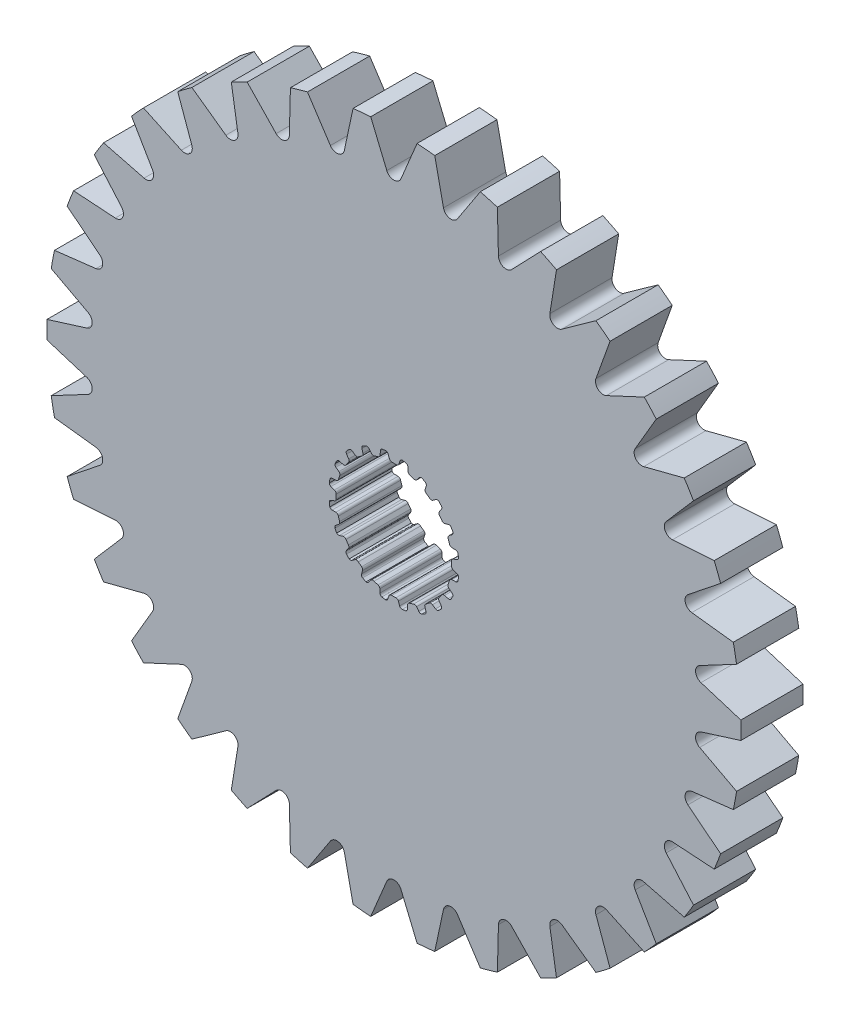
from build123d import *

# Parameters (mm, degrees)
SKETCH1_R           = 17.852401406
BOSS_EXTRUDE1_DEPTH = 1.6002
CUT_EXTRUDE1_DEPTH  = 3.2004


with BuildPart() as part:
    # Sketch1 → Boss-Extrude1 (new body, symmetric)
    with BuildSketch(Plane.XY):
        Circle(SKETCH1_R)
        with BuildLine():
            Line((-0.106949245, 2.969874934), (0.106949245, 2.969874934))
            ThreePointArc((0.106949245, 2.969874934), (0.196343213, 2.986924176), (0.253739238, 3.057547504))
            Line((0.253739238, 3.057547504), (0.315888147, 3.237526941))
            ThreePointArc((0.315888147, 3.237526941), (0.359032156, 3.298322911), (0.4281449, 3.326269005))
            Line((0.4281449, 3.326269005), (0.620027588, 3.2937547))
            ThreePointArc((0.620027588, 3.2937547), (0.689621142, 3.24802576), (0.718272212, 3.169836791))
            Line((0.718272212, 3.169836791), (0.724389167, 2.979527391))
            ThreePointArc((0.724389167, 2.979527391), (0.750934762, 2.9040661), (0.816027049, 2.857568043))
            Line((0.816027049, 2.857568043), (1.019456602, 2.791469774))
            ThreePointArc((1.019456602, 2.791469774), (1.109743823, 2.780060312), (1.186154496, 2.829490741))
            Line((1.186154496, 2.829490741), (1.300878326, 2.981456288))
            ThreePointArc((1.300878326, 2.981456288), (1.360697704, 3.02594446), (1.435063648, 3.031165762))
            Line((1.435063648, 3.031165762), (1.607507455, 2.940947809))
            ThreePointArc((1.607507455, 2.940947809), (1.659563839, 2.875951412), (1.662650905, 2.792735615))
            Line((1.662650905, 2.792735615), (1.609659636, 2.609850378))
            ThreePointArc((1.609659636, 2.609850378), (1.611587176, 2.529879385), (1.659124931, 2.465542482))
            Line((1.659124931, 2.465542482), (1.832172444, 2.339816104))
            ThreePointArc((1.832172444, 2.339816104), (1.914514976, 2.301064775), (2.002460687, 2.32446371))
            Line((2.002460687, 2.32446371), (2.158529469, 2.433539921))
            ThreePointArc((2.158529469, 2.433539921), (2.229168681, 2.457365482), (2.301508367, 2.439350895))
            Line((2.301508367, 2.439350895), (2.437633293, 2.300260456))
            ThreePointArc((2.437633293, 2.300260456), (2.467056864, 2.222358901), (2.444277744, 2.14226202))
            Line((2.444277744, 2.14226202), (2.337365406, 1.984703026))
            ThreePointArc((2.337365406, 1.984703026), (2.314486209, 1.908050449), (2.339816104, 1.832172444))
            Line((2.339816104, 1.832172444), (2.465542482, 1.659124931))
            ThreePointArc((2.465542482, 1.659124931), (2.531880064, 1.596824985), (2.622752074, 1.591901975))
            Line((2.622752074, 1.591901975), (2.804888709, 1.64741171))
            ThreePointArc((2.804888709, 1.64741171), (2.879433095, 1.648242449), (2.942665411, 1.608755366))
            Line((2.942665411, 1.608755366), (3.0291466, 1.434407582))
            ThreePointArc((3.0291466, 1.434407582), (3.033057175, 1.351226417), (2.986641646, 1.282088892))
            Line((2.986641646, 1.282088892), (2.836273564, 1.165279113))
            ThreePointArc((2.836273564, 1.165279113), (2.790827206, 1.099448241), (2.791469774, 1.019456602))
            Line((2.791469774, 1.019456602), (2.857568043, 0.816027049))
            ThreePointArc((2.857568043, 0.816027049), (2.901407091, 0.736276839), (2.986310214, 0.703513784))
            Line((2.986310214, 0.703513784), (3.1766859, 0.700023363))
            ThreePointArc((3.1766859, 0.700023363), (3.247838536, 0.677777961), (3.295773863, 0.620683653))
            Line((3.295773863, 0.620683653), (3.324145932, 0.4281449))
            ThreePointArc((3.324145932, 0.4281449), (3.302160717, 0.347826477), (3.236652255, 0.29641597))
            Line((3.236652255, 0.29641597), (3.057547504, 0.231789562))
            ThreePointArc((3.057547504, 0.231789562), (2.993982591, 0.183224379), (2.969874934, 0.106949245))
            Line((2.969874934, 0.106949245), (2.969874934, -0.106949245))
            ThreePointArc((2.969874934, -0.106949245), (2.986924176, -0.196343213), (3.057547504, -0.253739238))
            Line((3.057547504, -0.253739238), (3.237526941, -0.315888147))
            ThreePointArc((3.237526941, -0.315888147), (3.298322911, -0.359032156), (3.326269005, -0.4281449))
            Line((3.326269005, -0.4281449), (3.2937547, -0.620027588))
            ThreePointArc((3.2937547, -0.620027588), (3.24802576, -0.689621142), (3.169836791, -0.718272212))
            Line((3.169836791, -0.718272212), (2.979527391, -0.724389167))
            ThreePointArc((2.979527391, -0.724389167), (2.9040661, -0.750934762), (2.857568043, -0.816027049))
            Line((2.857568043, -0.816027049), (2.791469774, -1.019456602))
            ThreePointArc((2.791469774, -1.019456602), (2.780060312, -1.109743823), (2.829490741, -1.186154496))
            Line((2.829490741, -1.186154496), (2.981456288, -1.300878326))
            ThreePointArc((2.981456288, -1.300878326), (3.02594446, -1.360697704), (3.031165762, -1.435063648))
            Line((3.031165762, -1.435063648), (2.940947809, -1.607507455))
            ThreePointArc((2.940947809, -1.607507455), (2.875951412, -1.659563839), (2.792735615, -1.662650905))
            Line((2.792735615, -1.662650905), (2.609850378, -1.609659636))
            ThreePointArc((2.609850378, -1.609659636), (2.529879385, -1.611587176), (2.465542482, -1.659124931))
            Line((2.465542482, -1.659124931), (2.339816104, -1.832172444))
            ThreePointArc((2.339816104, -1.832172444), (2.301064775, -1.914514976), (2.32446371, -2.002460687))
            Line((2.32446371, -2.002460687), (2.433539921, -2.158529469))
            ThreePointArc((2.433539921, -2.158529469), (2.457365482, -2.229168681), (2.439350895, -2.301508367))
            Line((2.439350895, -2.301508367), (2.300260456, -2.437633293))
            ThreePointArc((2.300260456, -2.437633293), (2.222358901, -2.467056864), (2.14226202, -2.444277744))
            Line((2.14226202, -2.444277744), (1.984703026, -2.337365406))
            ThreePointArc((1.984703026, -2.337365406), (1.908050449, -2.314486209), (1.832172444, -2.339816104))
            Line((1.832172444, -2.339816104), (1.659124931, -2.465542482))
            ThreePointArc((1.659124931, -2.465542482), (1.596824985, -2.531880064), (1.591901975, -2.622752074))
            Line((1.591901975, -2.622752074), (1.64741171, -2.804888709))
            ThreePointArc((1.64741171, -2.804888709), (1.648242449, -2.879433095), (1.608755366, -2.942665411))
            Line((1.608755366, -2.942665411), (1.434407582, -3.0291466))
            ThreePointArc((1.434407582, -3.0291466), (1.351226417, -3.033057175), (1.282088892, -2.986641646))
            Line((1.282088892, -2.986641646), (1.165279113, -2.836273564))
            ThreePointArc((1.165279113, -2.836273564), (1.099448241, -2.790827206), (1.019456602, -2.791469774))
            Line((1.019456602, -2.791469774), (0.816027049, -2.857568043))
            ThreePointArc((0.816027049, -2.857568043), (0.736276839, -2.901407091), (0.703513784, -2.986310214))
            Line((0.703513784, -2.986310214), (0.700023363, -3.1766859))
            ThreePointArc((0.700023363, -3.1766859), (0.677777961, -3.247838536), (0.620683653, -3.295773863))
            Line((0.620683653, -3.295773863), (0.4281449, -3.324145932))
            ThreePointArc((0.4281449, -3.324145932), (0.347826477, -3.302160717), (0.29641597, -3.236652255))
            Line((0.29641597, -3.236652255), (0.231789562, -3.057547504))
            ThreePointArc((0.231789562, -3.057547504), (0.183224379, -2.993982591), (0.106949245, -2.969874934))
            Line((0.106949245, -2.969874934), (-0.106949245, -2.969874934))
            ThreePointArc((-0.106949245, -2.969874934), (-0.196343213, -2.986924176), (-0.253739238, -3.057547504))
            Line((-0.253739238, -3.057547504), (-0.315888147, -3.237526941))
            ThreePointArc((-0.315888147, -3.237526941), (-0.359032156, -3.298322911), (-0.4281449, -3.326269005))
            Line((-0.4281449, -3.326269005), (-0.620027588, -3.2937547))
            ThreePointArc((-0.620027588, -3.2937547), (-0.689621142, -3.24802576), (-0.718272212, -3.169836791))
            Line((-0.718272212, -3.169836791), (-0.724389167, -2.979527391))
            ThreePointArc((-0.724389167, -2.979527391), (-0.750934762, -2.9040661), (-0.816027049, -2.857568043))
            Line((-0.816027049, -2.857568043), (-1.019456602, -2.791469774))
            ThreePointArc((-1.019456602, -2.791469774), (-1.109743823, -2.780060312), (-1.186154496, -2.829490741))
            Line((-1.186154496, -2.829490741), (-1.300878326, -2.981456288))
            ThreePointArc((-1.300878326, -2.981456288), (-1.360697704, -3.02594446), (-1.435063648, -3.031165762))
            Line((-1.435063648, -3.031165762), (-1.607507455, -2.940947809))
            ThreePointArc((-1.607507455, -2.940947809), (-1.659563839, -2.875951412), (-1.662650905, -2.792735615))
            Line((-1.662650905, -2.792735615), (-1.609659636, -2.609850378))
            ThreePointArc((-1.609659636, -2.609850378), (-1.611587176, -2.529879385), (-1.659124931, -2.465542482))
            Line((-1.659124931, -2.465542482), (-1.832172444, -2.339816104))
            ThreePointArc((-1.832172444, -2.339816104), (-1.914514976, -2.301064775), (-2.002460687, -2.32446371))
            Line((-2.002460687, -2.32446371), (-2.158529469, -2.433539921))
            ThreePointArc((-2.158529469, -2.433539921), (-2.229168681, -2.457365482), (-2.301508367, -2.439350895))
            Line((-2.301508367, -2.439350895), (-2.437633293, -2.300260456))
            ThreePointArc((-2.437633293, -2.300260456), (-2.467056864, -2.222358901), (-2.444277744, -2.14226202))
            Line((-2.444277744, -2.14226202), (-2.337365406, -1.984703026))
            ThreePointArc((-2.337365406, -1.984703026), (-2.314486209, -1.908050449), (-2.339816104, -1.832172444))
            Line((-2.339816104, -1.832172444), (-2.465542482, -1.659124931))
            ThreePointArc((-2.465542482, -1.659124931), (-2.531880064, -1.596824985), (-2.622752074, -1.591901975))
            Line((-2.622752074, -1.591901975), (-2.804888709, -1.64741171))
            ThreePointArc((-2.804888709, -1.64741171), (-2.879433095, -1.648242449), (-2.942665411, -1.608755366))
            Line((-2.942665411, -1.608755366), (-3.0291466, -1.434407582))
            ThreePointArc((-3.0291466, -1.434407582), (-3.033057175, -1.351226417), (-2.986641646, -1.282088892))
            Line((-2.986641646, -1.282088892), (-2.836273564, -1.165279113))
            ThreePointArc((-2.836273564, -1.165279113), (-2.790827206, -1.099448241), (-2.791469774, -1.019456602))
            Line((-2.791469774, -1.019456602), (-2.857568043, -0.816027049))
            ThreePointArc((-2.857568043, -0.816027049), (-2.901407091, -0.736276839), (-2.986310214, -0.703513784))
            Line((-2.986310214, -0.703513784), (-3.1766859, -0.700023363))
            ThreePointArc((-3.1766859, -0.700023363), (-3.247838536, -0.677777961), (-3.295773863, -0.620683653))
            Line((-3.295773863, -0.620683653), (-3.324145932, -0.4281449))
            ThreePointArc((-3.324145932, -0.4281449), (-3.302160717, -0.347826477), (-3.236652255, -0.29641597))
            Line((-3.236652255, -0.29641597), (-3.057547504, -0.231789562))
            ThreePointArc((-3.057547504, -0.231789562), (-2.993982591, -0.183224379), (-2.969874934, -0.106949245))
            Line((-2.969874934, -0.106949245), (-2.969874934, 0.106949245))
            ThreePointArc((-2.969874934, 0.106949245), (-2.986924176, 0.196343213), (-3.057547504, 0.253739238))
            Line((-3.057547504, 0.253739238), (-3.237526941, 0.315888147))
            ThreePointArc((-3.237526941, 0.315888147), (-3.298322911, 0.359032156), (-3.326269005, 0.4281449))
            Line((-3.326269005, 0.4281449), (-3.2937547, 0.620027588))
            ThreePointArc((-3.2937547, 0.620027588), (-3.24802576, 0.689621142), (-3.169836791, 0.718272212))
            Line((-3.169836791, 0.718272212), (-2.979527391, 0.724389167))
            ThreePointArc((-2.979527391, 0.724389167), (-2.9040661, 0.750934762), (-2.857568043, 0.816027049))
            Line((-2.857568043, 0.816027049), (-2.791469774, 1.019456602))
            ThreePointArc((-2.791469774, 1.019456602), (-2.780060312, 1.109743823), (-2.829490741, 1.186154496))
            Line((-2.829490741, 1.186154496), (-2.981456288, 1.300878326))
            ThreePointArc((-2.981456288, 1.300878326), (-3.02594446, 1.360697704), (-3.031165762, 1.435063648))
            Line((-3.031165762, 1.435063648), (-2.940947809, 1.607507455))
            ThreePointArc((-2.940947809, 1.607507455), (-2.875951412, 1.659563839), (-2.792735615, 1.662650905))
            Line((-2.792735615, 1.662650905), (-2.609850378, 1.609659636))
            ThreePointArc((-2.609850378, 1.609659636), (-2.529879385, 1.611587176), (-2.465542482, 1.659124931))
            Line((-2.465542482, 1.659124931), (-2.339816104, 1.832172444))
            ThreePointArc((-2.339816104, 1.832172444), (-2.301064775, 1.914514976), (-2.32446371, 2.002460687))
            Line((-2.32446371, 2.002460687), (-2.433539921, 2.158529469))
            ThreePointArc((-2.433539921, 2.158529469), (-2.457365482, 2.229168681), (-2.439350895, 2.301508367))
            Line((-2.439350895, 2.301508367), (-2.300260456, 2.437633293))
            ThreePointArc((-2.300260456, 2.437633293), (-2.222358901, 2.467056864), (-2.14226202, 2.444277744))
            Line((-2.14226202, 2.444277744), (-1.984703026, 2.337365406))
            ThreePointArc((-1.984703026, 2.337365406), (-1.908050449, 2.314486209), (-1.832172444, 2.339816104))
            Line((-1.832172444, 2.339816104), (-1.659124931, 2.465542482))
            ThreePointArc((-1.659124931, 2.465542482), (-1.596824985, 2.531880064), (-1.591901975, 2.622752074))
            Line((-1.591901975, 2.622752074), (-1.64741171, 2.804888709))
            ThreePointArc((-1.64741171, 2.804888709), (-1.648242449, 2.879433095), (-1.608755366, 2.942665411))
            Line((-1.608755366, 2.942665411), (-1.434407582, 3.0291466))
            ThreePointArc((-1.434407582, 3.0291466), (-1.351226417, 3.033057175), (-1.282088892, 2.986641646))
            Line((-1.282088892, 2.986641646), (-1.165279113, 2.836273564))
            ThreePointArc((-1.165279113, 2.836273564), (-1.099448241, 2.790827206), (-1.019456602, 2.791469774))
            Line((-1.019456602, 2.791469774), (-0.816027049, 2.857568043))
            ThreePointArc((-0.816027049, 2.857568043), (-0.736276839, 2.901407091), (-0.703513784, 2.986310214))
            Line((-0.703513784, 2.986310214), (-0.700023363, 3.1766859))
            ThreePointArc((-0.700023363, 3.1766859), (-0.677777961, 3.247838536), (-0.620683653, 3.295773863))
            Line((-0.620683653, 3.295773863), (-0.4281449, 3.324145932))
            ThreePointArc((-0.4281449, 3.324145932), (-0.347826477, 3.302160717), (-0.29641597, 3.236652255))
            Line((-0.29641597, 3.236652255), (-0.231789562, 3.057547504))
            ThreePointArc((-0.231789562, 3.057547504), (-0.183224379, 2.993982591), (-0.106949245, 2.969874934))
        make_face(mode=Mode.SUBTRACT)
    extrude(amount=BOSS_EXTRUDE1_DEPTH, both=True)

    # Sketch2 → Cut-Extrude1 (cut)
    with BuildSketch(Plane.XY.offset(1.6002)):
        with BuildLine():
            Line((-1.192370651, 17.812537388), (-0.364649349, 15.828937231))
            ThreePointArc((-0.364649349, 15.828937231), (0, 15.585975766), (0.364649349, 15.828937231))
            Line((0.364649349, 15.828937231), (1.192370651, 17.812537388))
            ThreePointArc((1.192370651, 17.812537388), (0, 17.852401406), (-1.192370651, 17.812537388))
        make_face()
        with BuildLine():
            Line((4.445113431, 17.290147557), (3.267000085, 15.492415353))
            ThreePointArc((3.267000085, 15.492415353), (2.863915532, 15.32059491), (2.550119083, 15.626423637))
            Line((2.550119083, 15.626423637), (2.100976882, 17.728342621))
            ThreePointArc((2.100976882, 17.728342621), (3.28037015, 17.548430347), (4.445113431, 17.290147557))
        make_face()
        with BuildLine():
            Line((7.546483204, 16.178962488), (6.058097051, 14.628317851))
            ThreePointArc((6.058097051, 14.628317851), (5.630303855, 14.53348957), (5.378046268, 14.891770928))
            Line((5.378046268, 14.891770928), (5.322778166, 17.04043041))
            ThreePointArc((5.322778166, 17.04043041), (6.449031229, 16.646868539), (7.546483204, 16.178962488))
        make_face()
        with BuildLine():
            Line((10.390866543, 14.516822257), (8.642892788, 13.266070529))
            ThreePointArc((8.642892788, 13.266070529), (8.204958933, 13.251463673), (8.022830537, 13.64999682))
            Line((8.022830537, 13.64999682), (8.363318624, 15.772226778))
            ThreePointArc((8.363318624, 15.772226778), (9.398078285, 15.178417589), (10.390866543, 14.516822257))
        make_face()
        with BuildLine():
            Line((12.881401384, 12.360329055), (10.933365177, 11.452063086))
            ThreePointArc((10.933365177, 11.452063086), (10.500203976, 11.518175075), (10.394406936, 11.943388442))
            Line((10.394406936, 11.943388442), (11.119056297, 13.966918881))
            ThreePointArc((11.119056297, 13.966918881), (12.027085056, 13.193083833), (12.881401384, 12.360329055))
        make_face()
        with BuildLine():
            Line((14.93327555, 9.782919671), (12.851514928, 9.24806937))
            ThreePointArc((12.851514928, 9.24806937), (12.437877165, 9.392648838), (12.412014272, 9.830062295))
            Line((12.412014272, 9.830062295), (13.496147843, 11.685984312))
            ThreePointArc((13.496147843, 11.685984312), (14.24652387, 10.75847543), (14.93327555, 9.782919671))
        make_face()
        with BuildLine():
            Line((16.476614929, 6.872364691), (14.332021752, 6.729143744))
            ThreePointArc((14.332021752, 6.729143744), (13.951993366, 6.947267211), (14.006945349, 7.381985167))
            Line((14.006945349, 7.381985167), (15.413644262, 9.007097564))
            ThreePointArc((15.413644262, 9.007097564), (15.980814401, 7.957500049), (16.476614929, 6.872364691))
        make_face()
        with BuildLine():
            Line((17.458862947, 3.727779574), (15.324468765, 3.981065198))
            ThreePointArc((15.324468765, 3.981065198), (14.990991166, 4.265304731), (15.124886702, 4.682523387))
            Line((15.124886702, 4.682523387), (16.806247512, 6.02148491))
            ThreePointArc((16.806247512, 6.02148491), (17.170897464, 4.885541549), (17.458862947, 3.727779574))
        make_face()
        with BuildLine():
            Line((17.846570327, 0.456249395), (15.795059373, 1.097416251))
            ThreePointArc((15.795059373, 1.097416251), (15.519488741, 1.438092415), (15.727768178, 1.82360389))
            Line((15.727768178, 1.82360389), (17.626534159, 2.83081781))
            ThreePointArc((17.626534159, 2.83081781), (17.776246209, 1.64721179), (17.846570327, 0.456249395))
        make_face()
        with BuildLine():
            Line((17.626534159, -2.83081781), (15.727768178, -1.82360389))
            ThreePointArc((15.727768178, -1.82360389), (15.519488741, -1.438092415), (15.795059373, -1.097416251))
            Line((15.795059373, -1.097416251), (17.846570327, -0.456249395))
            ThreePointArc((17.846570327, -0.456249395), (17.776246209, -1.64721179), (17.626534159, -2.83081781))
        make_face()
        with BuildLine():
            Line((16.806247512, -6.02148491), (15.124886702, -4.682523387))
            ThreePointArc((15.124886702, -4.682523387), (14.990991166, -4.265304731), (15.324468765, -3.981065198))
            Line((15.324468765, -3.981065198), (17.458862947, -3.727779574))
            ThreePointArc((17.458862947, -3.727779574), (17.170897464, -4.885541549), (16.806247512, -6.02148491))
        make_face()
        with BuildLine():
            Line((15.413644262, -9.007097564), (14.006945349, -7.381985167))
            ThreePointArc((14.006945349, -7.381985167), (13.951993366, -6.947267211), (14.332021752, -6.729143744))
            Line((14.332021752, -6.729143744), (16.476614929, -6.872364691))
            ThreePointArc((16.476614929, -6.872364691), (15.980814401, -7.957500049), (15.413644262, -9.007097564))
        make_face()
        with BuildLine():
            Line((13.496147843, -11.685984312), (12.412014272, -9.830062295))
            ThreePointArc((12.412014272, -9.830062295), (12.437877165, -9.392648838), (12.851514928, -9.24806937))
            Line((12.851514928, -9.24806937), (14.93327555, -9.782919671))
            ThreePointArc((14.93327555, -9.782919671), (14.24652387, -10.75847543), (13.496147843, -11.685984312))
        make_face()
        with BuildLine():
            Line((11.119056297, -13.966918881), (10.394406936, -11.943388442))
            ThreePointArc((10.394406936, -11.943388442), (10.500203976, -11.518175075), (10.933365177, -11.452063086))
            Line((10.933365177, -11.452063086), (12.881401384, -12.360329055))
            ThreePointArc((12.881401384, -12.360329055), (12.027085056, -13.193083833), (11.119056297, -13.966918881))
        make_face()
        with BuildLine():
            Line((8.363318624, -15.772226778), (8.022830537, -13.64999682))
            ThreePointArc((8.022830537, -13.64999682), (8.204958933, -13.251463673), (8.642892788, -13.266070529))
            Line((8.642892788, -13.266070529), (10.390866543, -14.516822257))
            ThreePointArc((10.390866543, -14.516822257), (9.398078285, -15.178417589), (8.363318624, -15.772226778))
        make_face()
        with BuildLine():
            Line((5.322778166, -17.04043041), (5.378046268, -14.891770928))
            ThreePointArc((5.378046268, -14.891770928), (5.630303855, -14.53348957), (6.058097051, -14.628317851))
            Line((6.058097051, -14.628317851), (7.546483204, -16.178962488))
            ThreePointArc((7.546483204, -16.178962488), (6.449031229, -16.646868539), (5.322778166, -17.04043041))
        make_face()
        with BuildLine():
            Line((2.100976882, -17.728342621), (2.550119083, -15.626423637))
            ThreePointArc((2.550119083, -15.626423637), (2.863915532, -15.32059491), (3.267000085, -15.492415353))
            Line((3.267000085, -15.492415353), (4.445113431, -17.290147557))
            ThreePointArc((4.445113431, -17.290147557), (3.28037015, -17.548430347), (2.100976882, -17.728342621))
        make_face()
        with BuildLine():
            Line((-1.192370651, -17.812537388), (-0.364649349, -15.828937231))
            ThreePointArc((-0.364649349, -15.828937231), (0, -15.585975766), (0.364649349, -15.828937231))
            Line((0.364649349, -15.828937231), (1.192370651, -17.812537388))
            ThreePointArc((1.192370651, -17.812537388), (0, -17.852401406), (-1.192370651, -17.812537388))
        make_face()
        with BuildLine():
            Line((-4.445113431, -17.290147557), (-3.267000085, -15.492415353))
            ThreePointArc((-3.267000085, -15.492415353), (-2.863915532, -15.32059491), (-2.550119083, -15.626423637))
            Line((-2.550119083, -15.626423637), (-2.100976882, -17.728342621))
            ThreePointArc((-2.100976882, -17.728342621), (-3.28037015, -17.548430347), (-4.445113431, -17.290147557))
        make_face()
        with BuildLine():
            Line((-7.546483204, -16.178962488), (-6.058097051, -14.628317851))
            ThreePointArc((-6.058097051, -14.628317851), (-5.630303855, -14.53348957), (-5.378046268, -14.891770928))
            Line((-5.378046268, -14.891770928), (-5.322778166, -17.04043041))
            ThreePointArc((-5.322778166, -17.04043041), (-6.449031229, -16.646868539), (-7.546483204, -16.178962488))
        make_face()
        with BuildLine():
            Line((-10.390866543, -14.516822257), (-8.642892788, -13.266070529))
            ThreePointArc((-8.642892788, -13.266070529), (-8.204958933, -13.251463673), (-8.022830537, -13.64999682))
            Line((-8.022830537, -13.64999682), (-8.363318624, -15.772226778))
            ThreePointArc((-8.363318624, -15.772226778), (-9.398078285, -15.178417589), (-10.390866543, -14.516822257))
        make_face()
        with BuildLine():
            Line((-12.881401384, -12.360329055), (-10.933365177, -11.452063086))
            ThreePointArc((-10.933365177, -11.452063086), (-10.500203976, -11.518175075), (-10.394406936, -11.943388442))
            Line((-10.394406936, -11.943388442), (-11.119056297, -13.966918881))
            ThreePointArc((-11.119056297, -13.966918881), (-12.027085056, -13.193083833), (-12.881401384, -12.360329055))
        make_face()
        with BuildLine():
            Line((-14.93327555, -9.782919671), (-12.851514928, -9.24806937))
            ThreePointArc((-12.851514928, -9.24806937), (-12.437877165, -9.392648838), (-12.412014272, -9.830062295))
            Line((-12.412014272, -9.830062295), (-13.496147843, -11.685984312))
            ThreePointArc((-13.496147843, -11.685984312), (-14.24652387, -10.75847543), (-14.93327555, -9.782919671))
        make_face()
        with BuildLine():
            Line((-16.476614929, -6.872364691), (-14.332021752, -6.729143744))
            ThreePointArc((-14.332021752, -6.729143744), (-13.951993366, -6.947267211), (-14.006945349, -7.381985167))
            Line((-14.006945349, -7.381985167), (-15.413644262, -9.007097564))
            ThreePointArc((-15.413644262, -9.007097564), (-15.980814401, -7.957500049), (-16.476614929, -6.872364691))
        make_face()
        with BuildLine():
            Line((-17.458862947, -3.727779574), (-15.324468765, -3.981065198))
            ThreePointArc((-15.324468765, -3.981065198), (-14.990991166, -4.265304731), (-15.124886702, -4.682523387))
            Line((-15.124886702, -4.682523387), (-16.806247512, -6.02148491))
            ThreePointArc((-16.806247512, -6.02148491), (-17.170897464, -4.885541549), (-17.458862947, -3.727779574))
        make_face()
        with BuildLine():
            Line((-17.846570327, -0.456249395), (-15.795059373, -1.097416251))
            ThreePointArc((-15.795059373, -1.097416251), (-15.519488741, -1.438092415), (-15.727768178, -1.82360389))
            Line((-15.727768178, -1.82360389), (-17.626534159, -2.83081781))
            ThreePointArc((-17.626534159, -2.83081781), (-17.776246209, -1.64721179), (-17.846570327, -0.456249395))
        make_face()
        with BuildLine():
            Line((-17.626534159, 2.83081781), (-15.727768178, 1.82360389))
            ThreePointArc((-15.727768178, 1.82360389), (-15.519488741, 1.438092415), (-15.795059373, 1.097416251))
            Line((-15.795059373, 1.097416251), (-17.846570327, 0.456249395))
            ThreePointArc((-17.846570327, 0.456249395), (-17.776246209, 1.64721179), (-17.626534159, 2.83081781))
        make_face()
        with BuildLine():
            Line((-16.806247512, 6.02148491), (-15.124886702, 4.682523387))
            ThreePointArc((-15.124886702, 4.682523387), (-14.990991166, 4.265304731), (-15.324468765, 3.981065198))
            Line((-15.324468765, 3.981065198), (-17.458862947, 3.727779574))
            ThreePointArc((-17.458862947, 3.727779574), (-17.170897464, 4.885541549), (-16.806247512, 6.02148491))
        make_face()
        with BuildLine():
            Line((-15.413644262, 9.007097564), (-14.006945349, 7.381985167))
            ThreePointArc((-14.006945349, 7.381985167), (-13.951993366, 6.947267211), (-14.332021752, 6.729143744))
            Line((-14.332021752, 6.729143744), (-16.476614929, 6.872364691))
            ThreePointArc((-16.476614929, 6.872364691), (-15.980814401, 7.957500049), (-15.413644262, 9.007097564))
        make_face()
        with BuildLine():
            Line((-13.496147843, 11.685984312), (-12.412014272, 9.830062295))
            ThreePointArc((-12.412014272, 9.830062295), (-12.437877165, 9.392648838), (-12.851514928, 9.24806937))
            Line((-12.851514928, 9.24806937), (-14.93327555, 9.782919671))
            ThreePointArc((-14.93327555, 9.782919671), (-14.24652387, 10.75847543), (-13.496147843, 11.685984312))
        make_face()
        with BuildLine():
            Line((-11.119056297, 13.966918881), (-10.394406936, 11.943388442))
            ThreePointArc((-10.394406936, 11.943388442), (-10.500203976, 11.518175075), (-10.933365177, 11.452063086))
            Line((-10.933365177, 11.452063086), (-12.881401384, 12.360329055))
            ThreePointArc((-12.881401384, 12.360329055), (-12.027085056, 13.193083833), (-11.119056297, 13.966918881))
        make_face()
        with BuildLine():
            Line((-8.363318624, 15.772226778), (-8.022830537, 13.64999682))
            ThreePointArc((-8.022830537, 13.64999682), (-8.204958933, 13.251463673), (-8.642892788, 13.266070529))
            Line((-8.642892788, 13.266070529), (-10.390866543, 14.516822257))
            ThreePointArc((-10.390866543, 14.516822257), (-9.398078285, 15.178417589), (-8.363318624, 15.772226778))
        make_face()
        with BuildLine():
            Line((-5.322778166, 17.04043041), (-5.378046268, 14.891770928))
            ThreePointArc((-5.378046268, 14.891770928), (-5.630303855, 14.53348957), (-6.058097051, 14.628317851))
            Line((-6.058097051, 14.628317851), (-7.546483204, 16.178962488))
            ThreePointArc((-7.546483204, 16.178962488), (-6.449031229, 16.646868539), (-5.322778166, 17.04043041))
        make_face()
        with BuildLine():
            Line((-2.100976882, 17.728342621), (-2.550119083, 15.626423637))
            ThreePointArc((-2.550119083, 15.626423637), (-2.863915532, 15.32059491), (-3.267000085, 15.492415353))
            Line((-3.267000085, 15.492415353), (-4.445113431, 17.290147557))
            ThreePointArc((-4.445113431, 17.290147557), (-3.28037015, 17.548430347), (-2.100976882, 17.728342621))
        make_face()
    extrude(amount=-CUT_EXTRUDE1_DEPTH, mode=Mode.SUBTRACT)


solid = part.part
